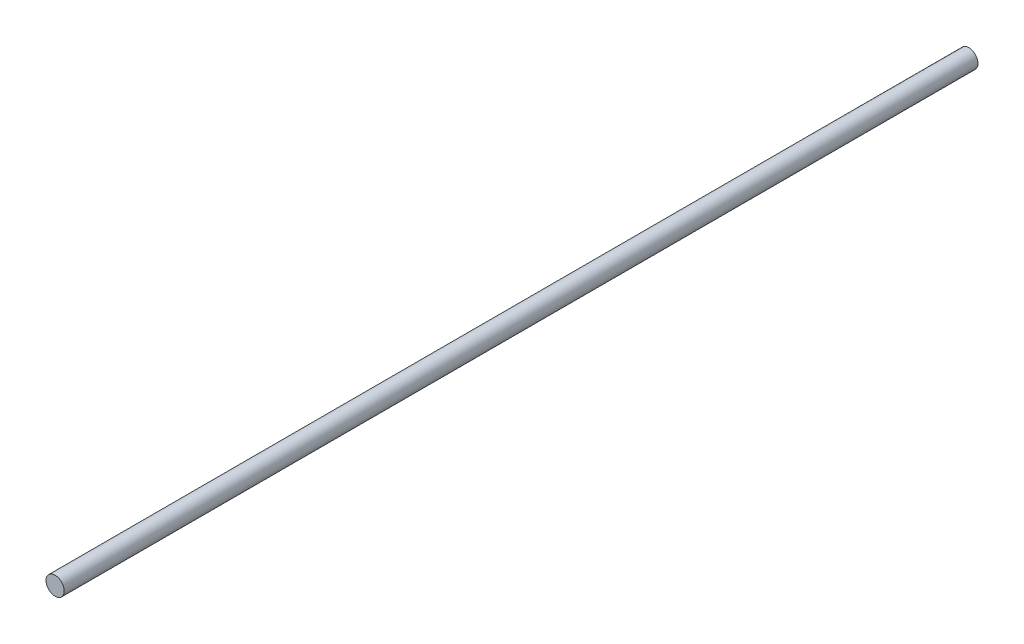
from build123d import *

# Parameters (mm, degrees)
SCHIZZO1_R                   = 0.5
ESTRUSIONE_ESTRUSIONE1_DEPTH = 50


with BuildPart() as part:
    # Schizzo1 → Estrusione-Estrusione1 (new body)
    with BuildSketch(Plane.XY):
        Circle(SCHIZZO1_R)
    extrude(amount=ESTRUSIONE_ESTRUSIONE1_DEPTH)


solid = part.part
